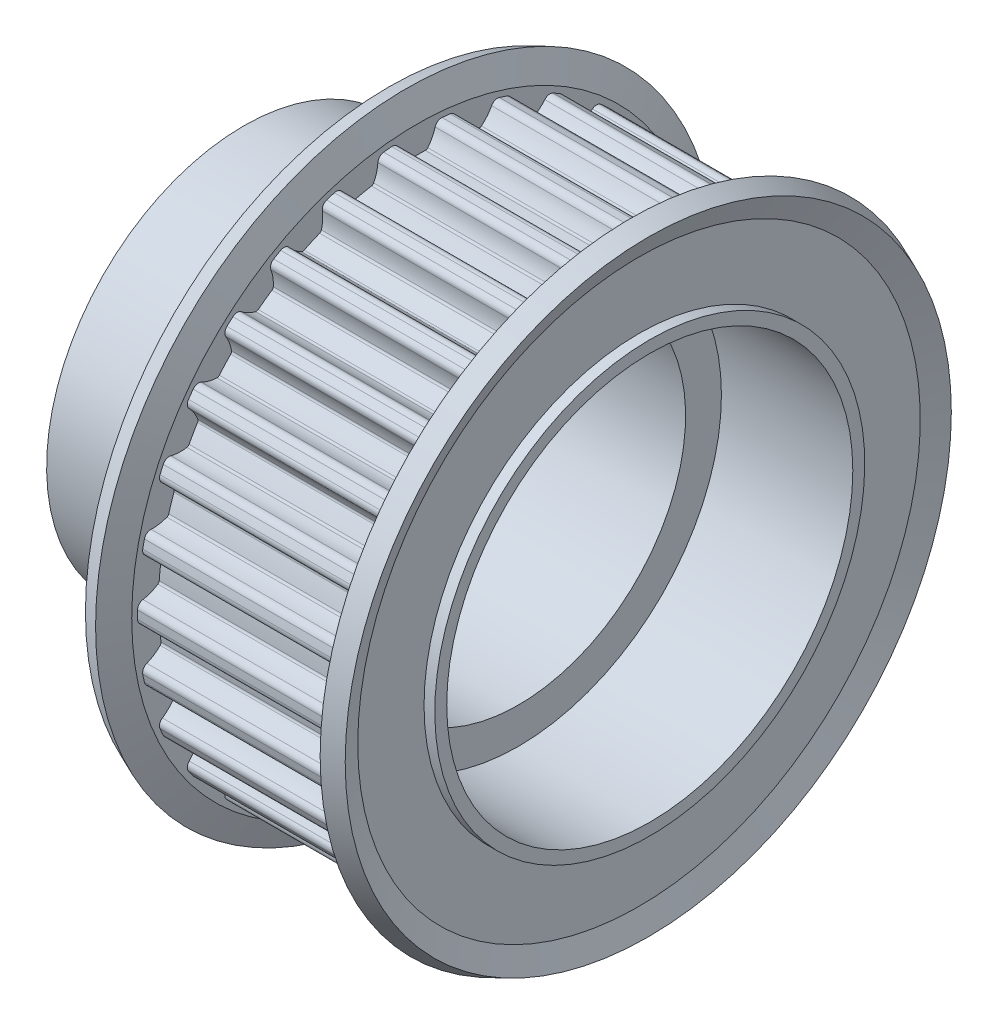
from build123d import *

# Parameters (mm, degrees)
CUT_EXTRUDE1_REACH         = 40.404
CIRPATTERN1_COUNT          = 30
SKETCH7_R                  = 17
CUT_EXTRUDE2_DEPTH         = 11
M5X0_8_TAPPED_HOLE1_REACH  = 62.318
M5X0_8_TAPPED_HOLE1_BORE_R = 2.1


with BuildPart() as part:
    # Sketch1 → Revolve1 (revolve)
    with BuildSketch(Plane.XY):
        Polygon((0, 0), (0, 16.5), (12, 16.5), (12, 18), (14.5, 18), (14.5, 23.395), (31.5, 23.395), (31.5, 18), (34, 18), (34, 0), align=None)
    revolve(axis=Axis((37, 0, 0), (-1, 0, 0)))

    # Sketch2 → Cut-Extrude1 (cut, up to next)
    with BuildSketch(Plane.ZY.offset(-14.5), mode=Mode.PRIVATE) as cut_extrude1_sk1:
        with BuildLine():
            ThreePointArc((-1.53043503, 22.89915634), (-1.283225644, 22.270062208), (-0.912136616, 21.705115449))
            ThreePointArc((-0.912136616, 21.705115449), (-0.821927913, 21.63561349), (-0.71025107, 21.613333117))
            ThreePointArc((-0.71025107, 21.613333117), (0, 21.625), (0.71025107, 21.613333117))
            ThreePointArc((0.71025107, 21.613333117), (0.821927913, 21.63561349), (0.912136616, 21.705115449))
            ThreePointArc((0.912136616, 21.705115449), (1.283225644, 22.270062208), (1.53043503, 22.89915634))
            ThreePointArc((1.53043503, 22.89915634), (1.747662939, 23.204363869), (2.10995907, 23.299658747))
            ThreePointArc((2.10995907, 23.299658747), (0, 23.395), (-2.10995907, 23.299658747))
            ThreePointArc((-2.10995907, 23.299658747), (-1.747662939, 23.204363869), (-1.53043503, 22.89915634))
        make_face()
    cut_extrude1_tool1 = extrude(cut_extrude1_sk1.sketch, amount=-CUT_EXTRUDE1_REACH, mode=Mode.PRIVATE) & part.part
    cut_extrude1 = cut_extrude1_tool1.solids().sort_by_distance((14.5, 22.595393, 0))[0]
    add(cut_extrude1, mode=Mode.SUBTRACT)

    # CirPattern1: Cut-Extrude1 ×30 about axis
    cirpattern1_axis = Axis((0, 0, 0), (1, 0, 0))
    for i in range(1, CIRPATTERN1_COUNT):
        add(cut_extrude1.rotate(cirpattern1_axis, i * 360 / CIRPATTERN1_COUNT), mode=Mode.SUBTRACT)

    # Sketch3 → Revolve2 (revolve)
    with BuildSketch(Plane.XY, mode=Mode.PRIVATE) as revolve2_sk:
        Polygon((14.5, 17.999488308), (14.5, 23.875), (13.597991016, 26), (12.12518325, 25.374830194), (12.9, 23.549476321), (12.9, 17.999488308), align=None)
        Polygon((31.5, 17.999488308), (31.5, 23.875), (32.402008984, 26), (33.87481675, 25.374830194), (33.1, 23.549476321), (33.1, 17.999488308), align=None)
    revolve(revolve2_sk.sketch.rotate(Axis((-7.268208351, 0, 0), (1, 0, 0)), 90), axis=Axis((-7.268208351, 0, 0), (1, 0, 0)))

    # Sketch4 → Cut-Revolve1 (revolve, cut)
    with BuildSketch(Plane.XY, mode=Mode.PRIVATE) as cut_revolve1_sk:
        Polygon((0, 0), (0, 7), (12, 7), (12, 14), (34, 14), (34, 0), align=None)
    revolve(cut_revolve1_sk.sketch.rotate(Axis((-13.694320048, 0, 0), (1, 0, 0)), 90), axis=Axis((-13.694320048, 0, 0), (1, 0, 0)), mode=Mode.SUBTRACT)

    # Sketch7 → Cut-Extrude2 (cut)
    with BuildSketch(Plane(origin=(34, 0, 0), x_dir=(0, 0, -1), z_dir=(1, 0, 0))):
        with Locations(Location((0, 0, 0), (0, 0, 90))):
            Circle(SKETCH7_R)
    extrude(amount=-CUT_EXTRUDE2_DEPTH, mode=Mode.SUBTRACT)

    # M5x0.8 Tapped Hole1 bore → M5x0.8 Tapped Hole1 (cut, up to next)
    with BuildSketch(Plane(origin=(0, 16.5, 0), x_dir=(-1, 0, 0), z_dir=(0, 1, 0)), mode=Mode.PRIVATE) as m5x0_8_tapped_hole1_sk1:
        with Locations((-7, 0)):
            Circle(M5X0_8_TAPPED_HOLE1_BORE_R)
    m5x0_8_tapped_hole1_tool1 = extrude(m5x0_8_tapped_hole1_sk1.sketch, amount=-M5X0_8_TAPPED_HOLE1_REACH, mode=Mode.PRIVATE) & part.part
    add(m5x0_8_tapped_hole1_tool1.solids().sort_by_distance((7, 16.5, 0))[0], mode=Mode.SUBTRACT)


solid = part.part
